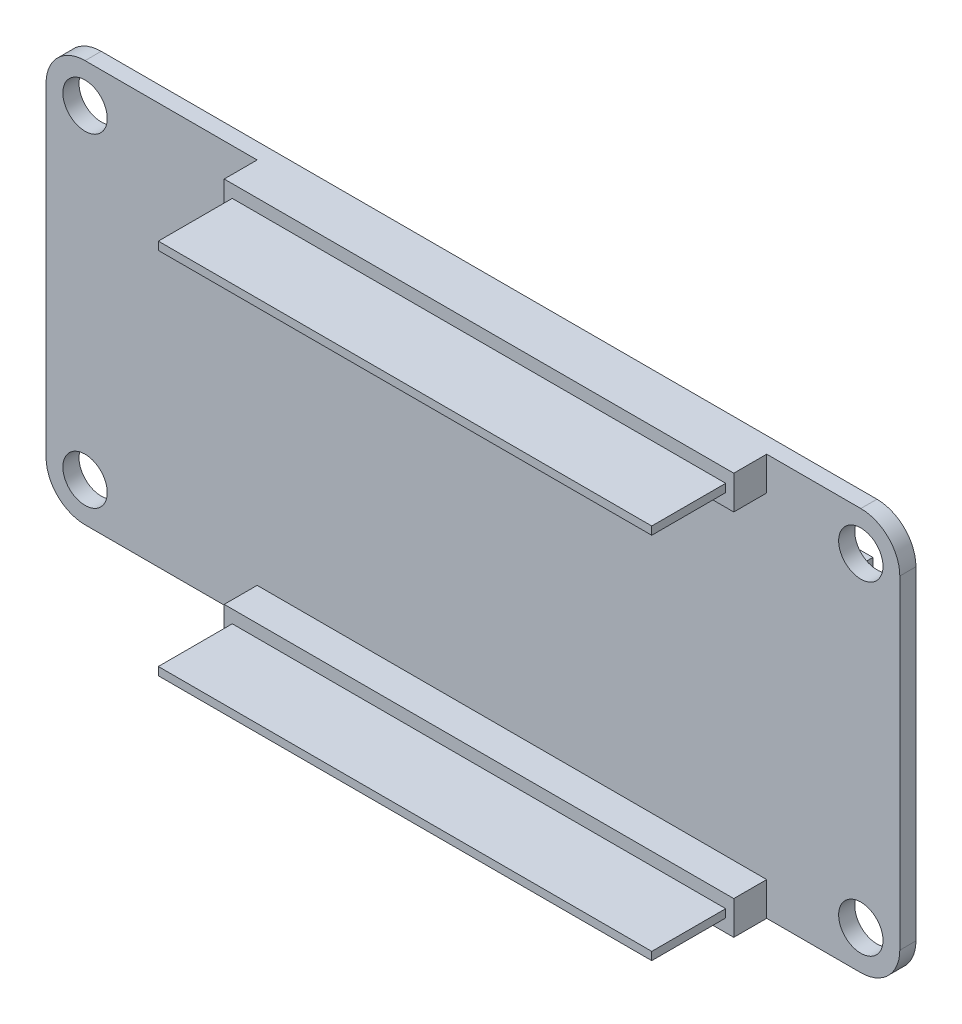
from build123d import *

# Parameters (mm, degrees)
SKETCH_1_R      = 1.65
EXTRUDE_1_DEPTH = 1.2
SKETCH_2_W      = 17.6
SKETCH_2_H      = 16
SKETCH_2_W_2    = 26.5
SKETCH_2_H_2    = 19.9
EXTRUDE_2_DEPTH = 2.3
SKETCH_3_W      = 17.6
SKETCH_3_H      = 16
EXTRUDE_3_DEPTH = 0.75
SKETCH_5_W      = 37.9
SKETCH_5_H      = 2.5
EXTRUDE_4_DEPTH = 2.45
SKETCH_6_W      = 36.7
SKETCH_6_H      = 0.6
EXTRUDE_5_DEPTH = 5.5


with BuildPart() as part:
    # 草图1 → 凸台-拉伸1 (new body)
    with BuildSketch(Plane.XY):
        with BuildLine():
            Line((0, -2.9), (57.7, -2.9))
            ThreePointArc((57.7, -2.9), (59.750609665, -2.050609665), (60.6, 0))
            Line((60.6, 0), (60.6, 24.1))
            ThreePointArc((60.6, 24.1), (59.750609665, 26.150609665), (57.7, 27))
            Line((57.7, 27), (0, 27))
            ThreePointArc((0, 27), (-2.050609665, 26.150609665), (-2.9, 24.1))
            Line((-2.9, 24.1), (-2.9, 0))
            ThreePointArc((-2.9, 0), (-2.050609665, -2.050609665), (0, -2.9))
        make_face()
        Circle(SKETCH_1_R, mode=Mode.SUBTRACT)
        with Locations((57.7, 0)):
            Circle(SKETCH_1_R, mode=Mode.SUBTRACT)
        with Locations((57.7, 24.1)):
            Circle(SKETCH_1_R, mode=Mode.SUBTRACT)
        with Locations((0, 24.1)):
            Circle(SKETCH_1_R, mode=Mode.SUBTRACT)
    extrude(amount=EXTRUDE_1_DEPTH)

    # 草图2 → 凸台-拉伸2 (add)
    with BuildSketch(Plane(origin=(0, 0, 0), x_dir=(-1, 0, 0), z_dir=(0, 0, -1))):
        with Locations((-45.55, 12.05)):
            Rectangle(SKETCH_2_W, SKETCH_2_H)
        with Locations((-19.85, 14.05)):
            Rectangle(SKETCH_2_W_2, SKETCH_2_H_2)
    extrude(amount=EXTRUDE_2_DEPTH)

    # 草图3 → 凸台-拉伸3 (add)
    with BuildSketch(Plane(origin=(0, 0, -2.3), x_dir=(-1, 0, 0), z_dir=(0, 0, -1))):
        with Locations((-45.55, 12.05)):
            Rectangle(SKETCH_3_W, SKETCH_3_H)
    extrude(amount=EXTRUDE_3_DEPTH)

    # 草图5 → 凸台-拉伸4 (add)
    with BuildSketch(Plane.XY.offset(1.2)):
        with Locations((31.75, 25.75)):
            Rectangle(SKETCH_5_W, SKETCH_5_H)
        with Locations((31.75, -1.65)):
            Rectangle(SKETCH_5_W, SKETCH_5_H)
    extrude(amount=EXTRUDE_4_DEPTH)

    # 草图6 → 凸台-拉伸5 (add)
    with BuildSketch(Plane.XY.offset(3.65)):
        with Locations((31.75, -1.65)):
            Rectangle(SKETCH_6_W, SKETCH_6_H)
        with Locations((31.75, 25.75)):
            Rectangle(SKETCH_6_W, SKETCH_6_H)
    extrude(amount=EXTRUDE_5_DEPTH)


solid = part.part
